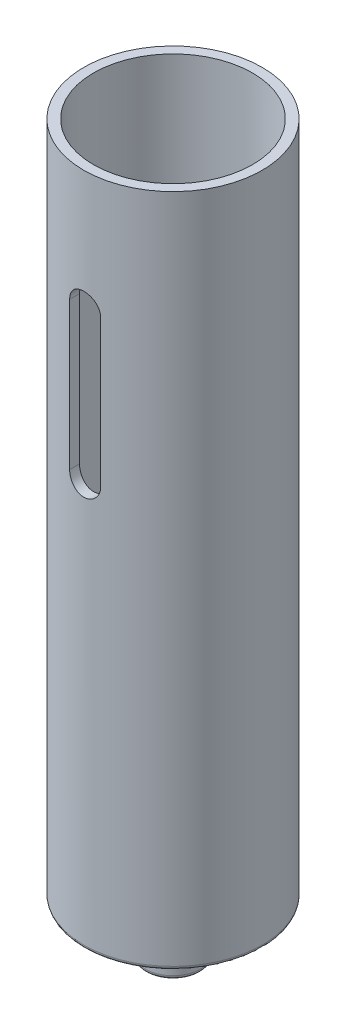
from build123d import *

# Parameters (mm, degrees)
SKETCH1_R               = 11.5
SKETCH1_R_2             = 10.25
BOSS_EXTRUDE1_DEPTH     = 87
SKETCH2_R               = 10.25
BOSS_EXTRUDE2_DEPTH     = 1.35
SKETCH3_R               = 3.55
BOSS_EXTRUDE3_DEPTH     = 6.66
CUT_EXTRUDE1_DEPTH      = 12.5
CUT_EXTRUDE1_DEPTH_BACK = 12.5
FILLET1_R               = 0.5


with BuildPart() as part:
    # Sketch1 → Boss-Extrude1 (new body)
    with BuildSketch(Plane(origin=(0, 0, 0), x_dir=(1, 0, 0), z_dir=(0, 1, 0))):
        Circle(SKETCH1_R)
        Circle(SKETCH1_R_2, mode=Mode.SUBTRACT)
    extrude(amount=BOSS_EXTRUDE1_DEPTH)

    # Sketch2 → Boss-Extrude2 (add)
    with BuildSketch(Plane.XZ):
        Circle(SKETCH2_R)
    extrude(amount=-BOSS_EXTRUDE2_DEPTH)

    # Sketch3 → Boss-Extrude3 (add)
    with BuildSketch(Plane.XZ):
        Circle(SKETCH3_R)
    extrude(amount=BOSS_EXTRUDE3_DEPTH)

    # Sketch4 → Cut-Extrude1 (cut, two sides)
    with BuildSketch(Plane.XY) as cut_extrude1_sk:
        with BuildLine():
            Line((-2, 71.5), (-2, 52.5))
            ThreePointArc((-2, 52.5), (0, 50.5), (2, 52.5))
            Line((2, 52.5), (2, 71.5))
            ThreePointArc((2, 71.5), (0, 73.5), (-2, 71.5))
        make_face()
    extrude(amount=CUT_EXTRUDE1_DEPTH, mode=Mode.SUBTRACT)
    extrude(cut_extrude1_sk.sketch, amount=-CUT_EXTRUDE1_DEPTH_BACK, mode=Mode.SUBTRACT)

    # Fillet1
    fillet1_edges = [part.edges().sort_by_distance(p)[0] for p in [
        (-3.55, 0, 0),
        (-3.55, -6.66, 0),
        (-11.5, 0, 0),
    ]]
    fillet(fillet1_edges, radius=FILLET1_R)


solid = part.part
